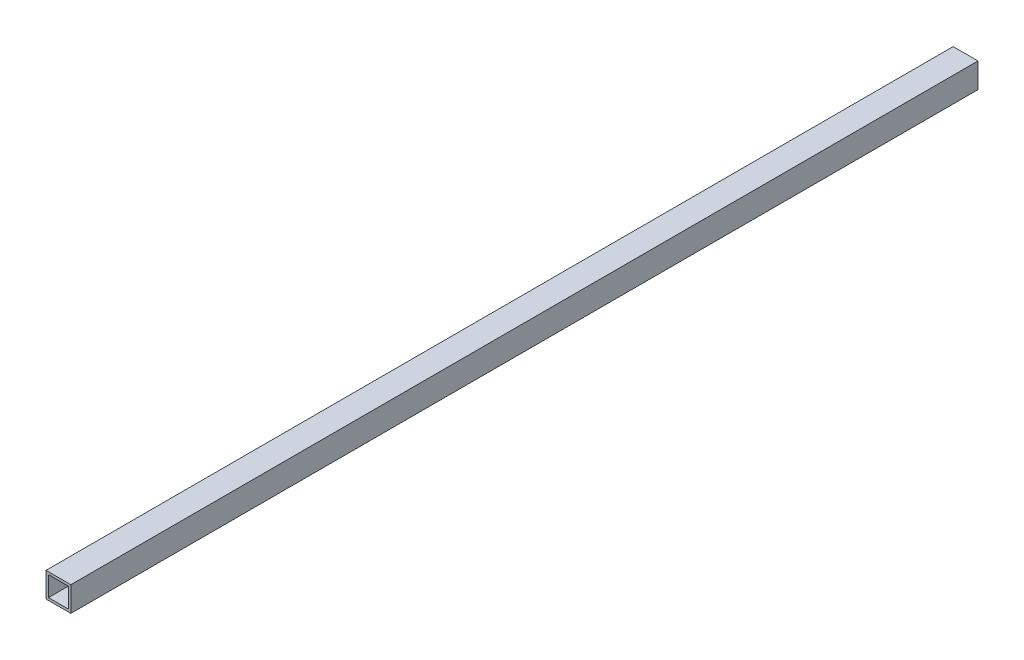
from build123d import *

# Parameters (mm, degrees)
SKETCH1_W           = 20
SKETCH1_H           = 20
SKETCH1_W_2         = 16
SKETCH1_H_2         = 16
BOSS_EXTRUDE1_DEPTH = 730


with BuildPart() as part:
    # Sketch1 → Boss-Extrude1 (new body)
    with BuildSketch(Plane.XY):
        Rectangle(SKETCH1_W, SKETCH1_H)
        Rectangle(SKETCH1_W_2, SKETCH1_H_2, mode=Mode.SUBTRACT)
    extrude(amount=BOSS_EXTRUDE1_DEPTH)


solid = part.part
